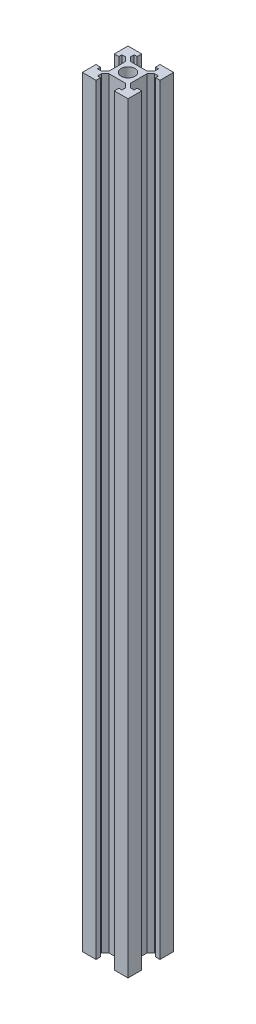
from build123d import *

# Parameters (mm, degrees)
SKETCH1_R           = 9
BOSS_EXTRUDE1_DEPTH = 1000


with BuildPart() as part:
    # Sketch1 → Boss-Extrude1 (new body)
    with BuildSketch(Plane(origin=(0, 0, 0), x_dir=(1, 0, 0), z_dir=(0, 1, 0))):
        Polygon((-30, 30), (-12, 30), (-12, 24), (-16, 24), (-16, 19), (-11, 14), (11, 14), (16, 19), (16, 24), (12, 24), (12, 30), (30, 30), (30, 12), (24, 12), (24, 16), (19, 16), (14, 11), (14, -11), (19, -16), (24, -16), (24, -12), (30, -12), (30, -30), (12, -30), (12, -24), (16, -24), (16, -19), (11, -14), (-11, -14), (-16, -19), (-16, -24), (-12, -24), (-12, -30), (-30, -30), (-30, -12), (-24, -12), (-24, -16), (-19, -16), (-14, -11), (-14, 11), (-19, 16), (-24, 16), (-24, 12), (-30, 12), align=None)
        Circle(SKETCH1_R, mode=Mode.SUBTRACT)
    extrude(amount=BOSS_EXTRUDE1_DEPTH)


solid = part.part
